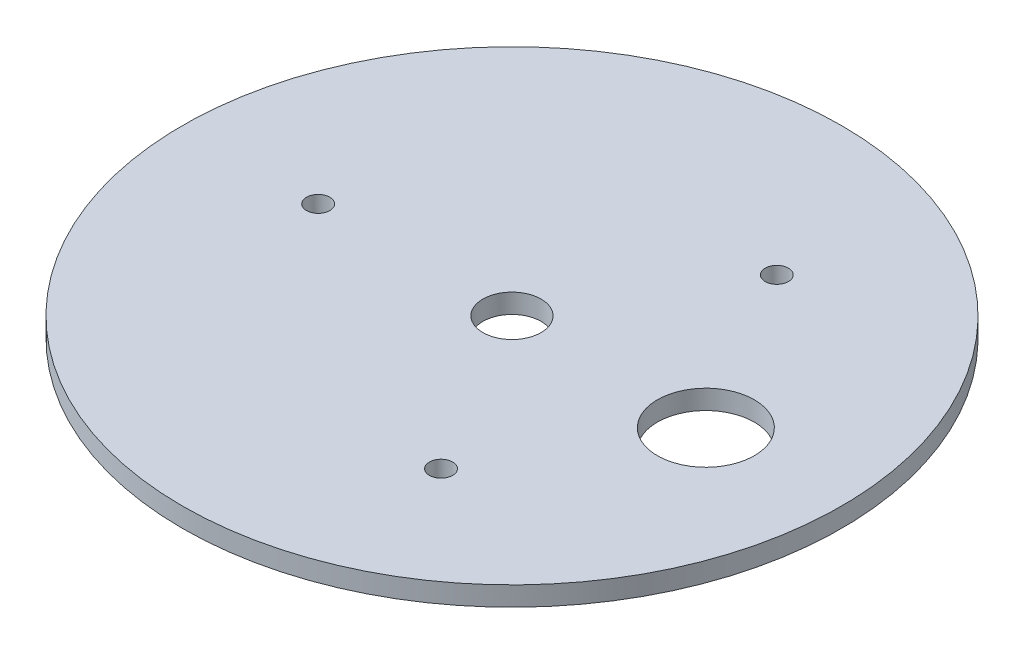
from build123d import *

# Parameters (mm, degrees)
SKETCH_1_W          = 85
SKETCH_1_H          = 5
SKETCH_2_R          = 12.5
SKETCH_2_R_2        = 7.5
SKETCH_2_R_3        = 3
CUT_EXTRUDE_1_DEPTH = 20


with BuildPart() as part:
    # 草图1 → 旋转1 (revolve)
    with BuildSketch(Plane.XY):
        with Locations((-42.5, 2.5)):
            Rectangle(SKETCH_1_W, SKETCH_1_H)
    revolve(axis=Axis((0, 0, 0), (0, 1, 0)))

    # 草图2 → 切除-拉伸1 (cut)
    with BuildSketch(Plane(origin=(0, 0, 0), x_dir=(1, 0, 0), z_dir=(0, 1, 0))):
        with Locations((50, 0)):
            Circle(SKETCH_2_R)
        Circle(SKETCH_2_R_2)
        with Locations((-50, 0)):
            Circle(SKETCH_2_R_3)
        with Locations((25, 43.301270189)):
            Circle(SKETCH_2_R_3)
        with Locations((25, -43.301270189)):
            Circle(SKETCH_2_R_3)
    extrude(amount=CUT_EXTRUDE_1_DEPTH, mode=Mode.SUBTRACT)


solid = part.part
